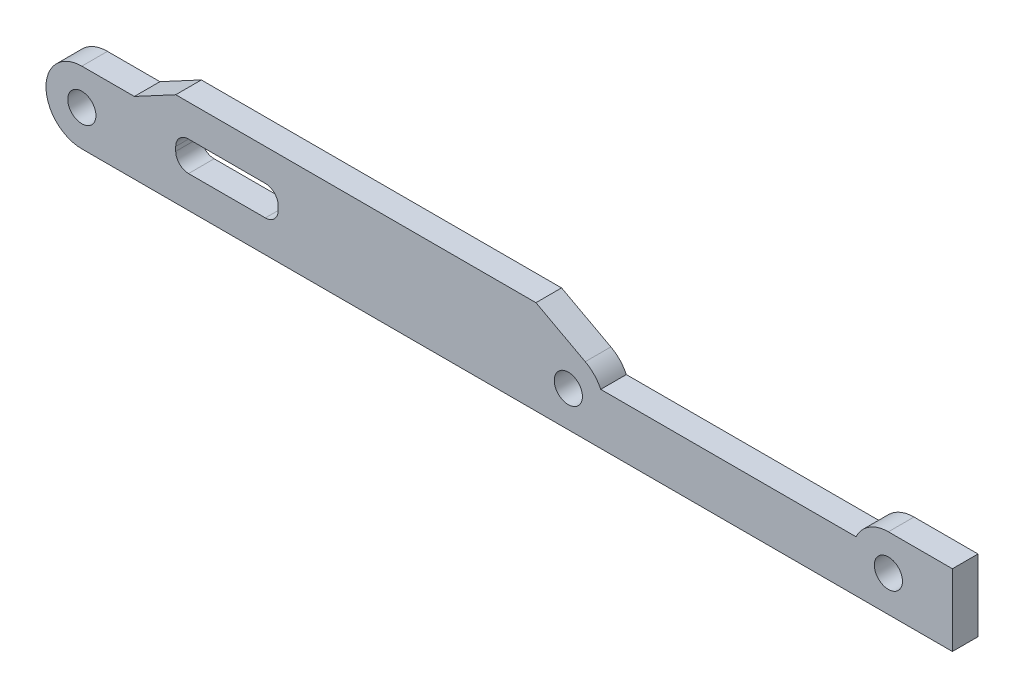
from build123d import *

# Parameters (mm, degrees)
SKETCH1_R           = 1.65
BOSS_EXTRUDE1_DEPTH = 3
FILLET1_R           = 1.5


with BuildPart() as part:
    # Sketch1 → Boss-Extrude1 (new body)
    with BuildSketch(Plane.XY):
        with BuildLine():
            Line((-57, -4.2), (45, -4.2))
            Line((45, -4.2), (45, 4.2))
            Line((45, 4.2), (37.5, 4.2))
            ThreePointArc((37.5, 4.2), (35.255005568, 3.54964787), (33.705266808, 1.8))
            Line((33.705266808, 1.8), (3.794733192, 1.8))
            ThreePointArc((3.794733192, 1.8), (3.042029577, 2.89586879), (1.984520956, 3.701577579))
            Line((1.984520956, 3.701577579), (-3.794733192, 6.8))
            Line((-3.794733192, 6.8), (-46, 6.8))
            Line((-46, 6.8), (-50.849584319, 4.2))
            Line((-50.849584319, 4.2), (-57, 4.2))
            ThreePointArc((-57, 4.2), (-61.2, 0), (-57, -4.2))
        make_face()
        Circle(SKETCH1_R, mode=Mode.SUBTRACT)
        with Locations((-57, 0)):
            Circle(SKETCH1_R, mode=Mode.SUBTRACT)
        with Locations((37.5, 0)):
            Circle(SKETCH1_R, mode=Mode.SUBTRACT)
        Polygon((-46, -0.45), (-34, -0.45), (-34, 1.8), (-34, 3.05), (-46, 3.05), (-46, 1.8), align=None, mode=Mode.SUBTRACT)
    extrude(amount=BOSS_EXTRUDE1_DEPTH)

    # Fillet1
    fillet1_edges = [part.edges().sort_by_distance(p)[0] for p in [
        (-34, -0.45, 1.5),
        (-34, 3.05, 1.5),
        (-46, 3.05, 1.5),
        (-46, -0.45, 1.5),
    ]]
    fillet(fillet1_edges, radius=FILLET1_R)


solid = part.part
